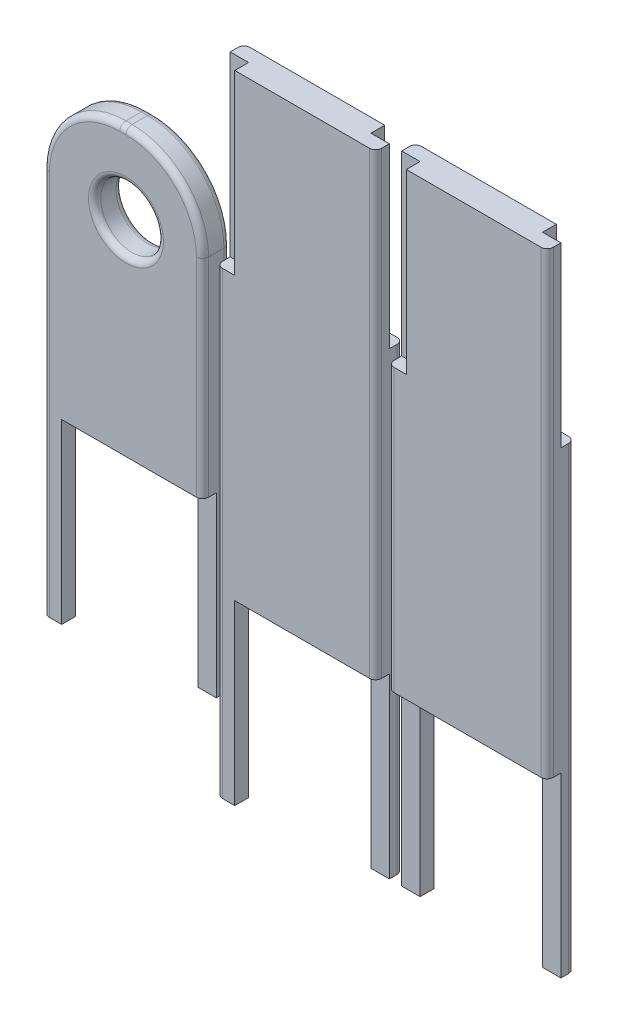
from build123d import *

# Parameters (mm, degrees)
SKETCH2_W            = 52
SKETCH2_H            = 150
BOSS_EXTRUDE1_DEPTH  = 9
SKETCH3_W            = 52
SKETCH3_H            = 150
BOSS_EXTRUDE2_DEPTH  = 9
SKETCH5_W            = 6
SKETCH5_H            = 58
BOSS_EXTRUDE3_DEPTH  = 4.5
SKETCH7_W            = 6
SKETCH7_H            = 58
CUT_EXTRUDE1_DEPTH   = 4.5
SKETCH8_W            = 6
SKETCH8_H            = 58
CUT_EXTRUDE2_DEPTH   = 4.5
SKETCH9_W            = 6
SKETCH9_H            = 58
BOSS_EXTRUDE4_DEPTH  = 4.5
SKETCH10_W           = 6
SKETCH10_H           = 58
BOSS_EXTRUDE5_DEPTH  = 4.5
BOSS_EXTRUDE8_DEPTH  = 9
SKETCH13_W           = 6
SKETCH13_H           = 58
CUT_EXTRUDE3_DEPTH   = 4.5
SKETCH14_W           = 6
SKETCH14_H           = 58
CUT_EXTRUDE4_DEPTH   = 4.5
SKETCH15_W           = 6
SKETCH15_H           = 58
BOSS_EXTRUDE9_DEPTH  = 4.5
SKETCH16_W           = 6
SKETCH16_H           = 58
BOSS_EXTRUDE10_DEPTH = 4.5
SKETCH17_R           = 10.25
CUT_EXTRUDE5_DEPTH   = 13.5
FILLET1_R            = 2
FILLET2_R            = 2
FILLET3_R            = 2


with BuildPart() as part:
    # Sketch2 → Boss-Extrude1 (new body)
    with BuildSketch(Plane.XY):
        with Locations((-54.980202323, -2.796759356)):
            Rectangle(SKETCH2_W, SKETCH2_H)
    extrude(amount=BOSS_EXTRUDE1_DEPTH)

    # Sketch9 → Boss-Extrude4 (add)
    with BuildSketch(Plane(origin=(0, 0, 0), x_dir=(-1, 0, 0), z_dir=(0, 0, -1))):
        with Locations((31.980202323, -106.796759356)):
            Rectangle(SKETCH9_W, SKETCH9_H)
    extrude(amount=-BOSS_EXTRUDE4_DEPTH)

    # Sketch10 → Boss-Extrude5 (add)
    with BuildSketch(Plane.XY.offset(9)):
        with Locations((-77.980202323, -106.796759356)):
            Rectangle(SKETCH10_W, SKETCH10_H)
    extrude(amount=-BOSS_EXTRUDE5_DEPTH)

    # Sketch13 → Cut-Extrude3 (cut)
    with BuildSketch(Plane(origin=(0, 0, 0), x_dir=(-1, 0, 0), z_dir=(0, 0, -1))):
        with Locations((31.980202323, 43.203240644)):
            Rectangle(SKETCH13_W, SKETCH13_H)
    extrude(amount=-CUT_EXTRUDE3_DEPTH, mode=Mode.SUBTRACT)

    # Sketch14 → Cut-Extrude4 (cut)
    with BuildSketch(Plane.XY.offset(9)):
        with Locations((-77.980202323, 43.203240644)):
            Rectangle(SKETCH14_W, SKETCH14_H)
    extrude(amount=-CUT_EXTRUDE4_DEPTH, mode=Mode.SUBTRACT)

    # Fillet2
    fillet2_edges = [part.edges().sort_by_distance(p)[0] for p in [
        (-28.980202323, -2.796759356, 9),
        (-80.980202323, -2.796759356, 0),
        (-80.980202323, -60.796759356, 9),
        (-28.980202323, -60.796759356, 0),
    ]]
    fillet(fillet2_edges, radius=FILLET2_R)


with BuildPart() as body_2:
    # Sketch3 → Boss-Extrude2 (new body)
    with BuildSketch(Plane.XY):
        with Locations((1.073700091, -2.796759356)):
            Rectangle(SKETCH3_W, SKETCH3_H)
    extrude(amount=BOSS_EXTRUDE2_DEPTH)

    # Sketch5 → Boss-Extrude3 (add)
    with BuildSketch(Plane(origin=(0, 0, 0), x_dir=(-1, 0, 0), z_dir=(0, 0, -1))):
        with Locations((21.926299909, -106.796759356)):
            Rectangle(SKETCH5_W, SKETCH5_H)
        with Locations((-24.073700091, -106.796759356)):
            Rectangle(SKETCH5_W, SKETCH5_H)
    extrude(amount=-BOSS_EXTRUDE3_DEPTH)

    # Sketch7 → Cut-Extrude1 (cut)
    with BuildSketch(Plane(origin=(0, 0, 0), x_dir=(-1, 0, 0), z_dir=(0, 0, -1))):
        with Locations((-24.073700091, 43.203240644)):
            Rectangle(SKETCH7_W, SKETCH7_H)
    extrude(amount=-CUT_EXTRUDE1_DEPTH, mode=Mode.SUBTRACT)

    # Sketch8 → Cut-Extrude2 (cut)
    with BuildSketch(Plane.XY.offset(9)):
        with Locations((-21.926299909, 43.203240644)):
            Rectangle(SKETCH8_W, SKETCH8_H)
    extrude(amount=-CUT_EXTRUDE2_DEPTH, mode=Mode.SUBTRACT)

    # Fillet3
    fillet3_edges = [body_2.edges().sort_by_distance(p)[0] for p in [
        (27.073700091, -2.796759356, 9),
        (-24.926299909, -31.796759356, 0),
        (-24.926299909, -31.796759356, 9),
        (27.073700091, -60.796759356, 0),
    ]]
    fillet(fillet3_edges, radius=FILLET3_R)


with BuildPart() as body_3:
    # Sketch12 → Boss-Extrude8 (new body)
    with BuildSketch(Plane.XY):
        with BuildLine():
            Line((-110.518525137, 38.172007968), (-112.518525137, 38.172007968))
            ThreePointArc((-112.518525137, 38.172007968), (-130.196194666, 30.849677498), (-137.518525137, 13.172007968))
            Line((-137.518525137, 13.172007968), (-137.518525137, -54.827992032))
            Line((-137.518525137, -54.827992032), (-85.518525137, -54.827992032))
            Line((-85.518525137, -54.827992032), (-85.518525137, 13.172007968))
            ThreePointArc((-85.518525137, 13.172007968), (-92.840855607, 30.849677498), (-110.518525137, 38.172007968))
        make_face()
    extrude(amount=BOSS_EXTRUDE8_DEPTH)

    # Sketch15 → Boss-Extrude9 (add)
    with BuildSketch(Plane.XY.offset(9)):
        with Locations((-134.518525137, -83.827992032)):
            Rectangle(SKETCH15_W, SKETCH15_H)
    extrude(amount=-BOSS_EXTRUDE9_DEPTH)

    # Sketch16 → Boss-Extrude10 (add)
    with BuildSketch(Plane(origin=(0, 0, 0), x_dir=(-1, 0, 0), z_dir=(0, 0, -1))):
        with Locations((88.518525137, -83.827992032)):
            Rectangle(SKETCH16_W, SKETCH16_H)
    extrude(amount=-BOSS_EXTRUDE10_DEPTH)

    # Sketch17 → Cut-Extrude5 (cut)
    with BuildSketch(Plane.XY.offset(9)):
        with Locations((-110.518525137, 12.172007968)):
            Circle(SKETCH17_R)
    extrude(amount=-CUT_EXTRUDE5_DEPTH, mode=Mode.SUBTRACT)

    # Fillet1
    fillet1_edges = [body_3.edges().sort_by_distance(p)[0] for p in [
        (-137.518525137, -49.827992032, 9),
        (-85.518525137, -20.827992032, 9),
        (-92.840855607, 30.849677498, 9),
        (-120.768525137, 12.172007968, 0),
        (-111.518525137, 38.172007968, 9),
        (-120.768525137, 12.172007968, 9),
        (-92.840855607, 30.849677498, 0),
        (-85.518525137, -49.827992032, 0),
        (-137.518525137, -20.827992032, 0),
        (-130.196194666, 30.849677498, 0),
        (-111.518525137, 38.172007968, 0),
        (-130.196194666, 30.849677498, 9),
    ]]
    fillet(fillet1_edges, radius=FILLET1_R)


solid = Compound([part.part, body_2.part, body_3.part])
